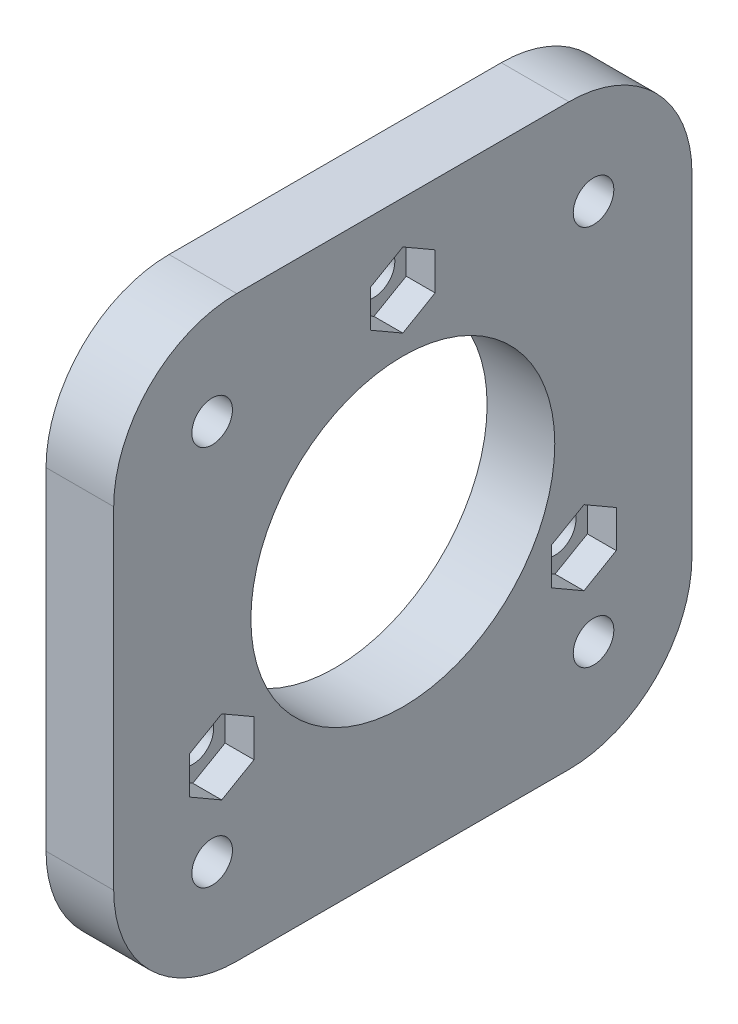
from build123d import *

# Parameters (mm, degrees)
CROQUIS1_W              = 47
CROQUIS1_H              = 47
CROQUIS1_R              = 1.65
SALIENTE_EXTRUIR1_DEPTH = 5.5
CORTAR_EXTRUIR1_DEPTH   = 2.35
CROQUIS7_R              = 12.35
CORTAR_EXTRUIR2_DEPTH   = 5.5
CROQUIS8_R              = 1.7
CORTAR_EXTRUIR3_DEPTH   = 5.5
CROQUIS9_R              = 3.25
CORTAR_EXTRUIR4_DEPTH   = 2.5
REDONDEO1_R             = 10


with BuildPart() as part:
    # Croquis1 → Saliente-Extruir1 (new body)
    with BuildSketch(Plane(origin=(0, 0, 0), x_dir=(0, 0, -1), z_dir=(1, 0, 0))):
        Rectangle(CROQUIS1_W, CROQUIS1_H)
        with Locations((-15.5, 15.5)):
            Circle(CROQUIS1_R, mode=Mode.SUBTRACT)
        with Locations((15.5, 15.5)):
            Circle(CROQUIS1_R, mode=Mode.SUBTRACT)
        with Locations((15.5, -15.5)):
            Circle(CROQUIS1_R, mode=Mode.SUBTRACT)
        with Locations((-15.5, -15.5)):
            Circle(CROQUIS1_R, mode=Mode.SUBTRACT)
    extrude(amount=SALIENTE_EXTRUIR1_DEPTH)

    # Croquis2 → Cortar-Extruir1 (cut)
    with BuildSketch(Plane(origin=(5.5, 0, 0), x_dir=(0, 0, -1), z_dir=(1, 0, 0))):
        Polygon((0, 13.968911087), (2.625, 15.484455543), (2.625, 18.515544457), (0, 20.031088913), (-2.625, 18.515544457), (-2.625, 15.484455543), align=None)
        Polygon((14.722431864, -11.531088913), (17.347431864, -10.015544457), (17.347431864, -6.984455543), (14.722431864, -5.468911087), (12.097431864, -6.984455543), (12.097431864, -10.015544457), align=None)
        Polygon((-17.347431864, -6.984455543), (-17.347431864, -10.015544457), (-14.722431864, -11.531088913), (-12.097431864, -10.015544457), (-12.097431864, -6.984455543), (-14.722431864, -5.468911087), align=None)
    extrude(amount=-CORTAR_EXTRUIR1_DEPTH, mode=Mode.SUBTRACT)

    # Croquis7 → Cortar-Extruir2 (cut)
    with BuildSketch(Plane(origin=(5.5, 0, 0), x_dir=(0, 0, -1), z_dir=(1, 0, 0))):
        Circle(CROQUIS7_R)
    extrude(amount=-CORTAR_EXTRUIR2_DEPTH, mode=Mode.SUBTRACT)

    # Croquis8 → Cortar-Extruir3 (cut)
    with BuildSketch(Plane(origin=(5.5, 0, 0), x_dir=(0, 0, -1), z_dir=(1, 0, 0))):
        with Locations((0, 17)):
            Circle(CROQUIS8_R)
        with Locations((14.722431864, -8.5)):
            Circle(CROQUIS8_R)
        with Locations((-14.722431864, -8.5)):
            Circle(CROQUIS8_R)
    extrude(amount=-CORTAR_EXTRUIR3_DEPTH, mode=Mode.SUBTRACT)

    # Croquis9 → Cortar-Extruir4 (cut)
    with BuildSketch(Plane.ZY):
        with Locations((-15.5, -15.5)):
            Circle(CROQUIS9_R)
        with Locations((-15.5, 15.5)):
            Circle(CROQUIS9_R)
        with Locations((15.5, 15.5)):
            Circle(CROQUIS9_R)
        with Locations((15.5, -15.5)):
            Circle(CROQUIS9_R)
    extrude(amount=-CORTAR_EXTRUIR4_DEPTH, mode=Mode.SUBTRACT)

    # Redondeo1
    redondeo1_edges = [part.edges().sort_by_distance(p)[0] for p in [
        (2.75, -23.5, 23.5),
        (2.75, 23.5, 23.5),
        (2.75, 23.5, -23.5),
        (2.75, -23.5, -23.5),
    ]]
    fillet(redondeo1_edges, radius=REDONDEO1_R)


solid = part.part
